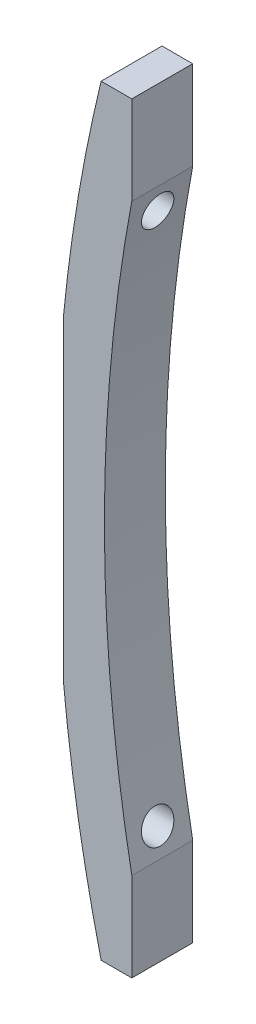
from build123d import *

# Parameters (mm, degrees)
BOSS_EXTRU_1_DEPTH      = 8
TROU_TARAUD_M51_D       = 4.2
TROU_TARAUD_M52_D       = 4.2
ESQUISSE8_W             = 18.974951104
ESQUISSE8_H             = 96.168502187
ENL_V_MAT_EXTRU_1_DEPTH = 34


with BuildPart() as part:
    # Esquisse1 → Boss.-Extru.1 (new body)
    with BuildSketch(Plane.XY):
        with BuildLine():
            Line((-202.4, -38.343708741), (-202.4, -50))
            Line((-202.4, -50), (-206.431005423, -50))
            ThreePointArc((-206.431005423, -50), (-212.4, 0), (-206.431005423, 50))
            Line((-206.431005423, 50), (-202.4, 50))
            Line((-202.4, 50), (-202.4, 38.343708741))
            ThreePointArc((-202.4, 38.343708741), (-206, 0), (-202.4, -38.343708741))
        make_face()
    extrude(amount=BOSS_EXTRU_1_DEPTH)

    # Trou taraudé M51 (through all)
    with Locations(Plane(origin=(-202.4, 0, 0), x_dir=(0, 0, -1), z_dir=(1, 0, 0))):
        with Locations((-4, 35)):
            Hole(TROU_TARAUD_M51_D / 2)

    # Trou taraudé M52 (through all)
    with Locations(Plane(origin=(-202.4, 0, 0), x_dir=(0, 0, -1), z_dir=(1, 0, 0))):
        with Locations((-4, -35)):
            Hole(TROU_TARAUD_M52_D / 2)

    # Esquisse8 → Enlèv. mat.-Extru.1 (cut)
    with BuildSketch(Plane.XY):
        with Locations((-220.887475552, -0.394191452)):
            Rectangle(ESQUISSE8_W, ESQUISSE8_H)
    extrude(amount=ENL_V_MAT_EXTRU_1_DEPTH, mode=Mode.SUBTRACT)


solid = part.part
